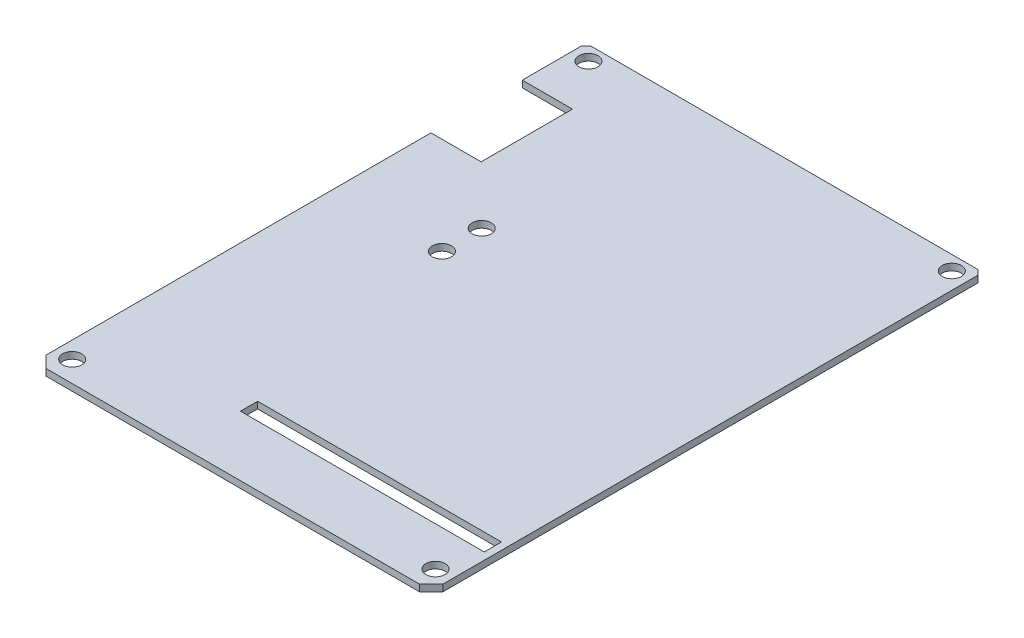
from build123d import *

# Parameters (mm, degrees)
SKETCH1_R           = 1
BOSS_EXTRUDE1_DEPTH = 0.7
SKETCH2_W           = 25.502878438
SKETCH2_H           = 1.8
CUT_EXTRUDE1_DEPTH  = 10
BOSS_EXTRUDE2_DEPTH = 0.7
SKETCH6_W           = 5.25
SKETCH6_H           = 9.55
CUT_EXTRUDE2_DEPTH  = 6


with BuildPart() as part:
    # Sketch1 → Boss-Extrude1 (new body)
    with BuildSketch(Plane(origin=(0, 0, 0), x_dir=(1, 0, 0), z_dir=(0, 1, 0))):
        Polygon((20.240139403, -28.5), (20.75, -27.990139403), (20.75, 27.990139403), (20.240139403, 28.5), (-20.240139403, 28.5), (-20.75, 27.990139403), (-20.75, -27.990139403), (-20.240139403, -28.5), align=None)
        with Locations((-19, -27)):
            Circle(SKETCH1_R, mode=Mode.SUBTRACT)
        with Locations((19, -27)):
            Circle(SKETCH1_R, mode=Mode.SUBTRACT)
        with Locations((-9.45, 2.115469811)):
            Circle(SKETCH1_R, mode=Mode.SUBTRACT)
        with Locations((-9.45, 6.284530189)):
            Circle(SKETCH1_R, mode=Mode.SUBTRACT)
        with Locations((-19, 27)):
            Circle(SKETCH1_R, mode=Mode.SUBTRACT)
        with Locations((19, 27)):
            Circle(SKETCH1_R, mode=Mode.SUBTRACT)
    extrude(amount=BOSS_EXTRUDE1_DEPTH)

    # Sketch2 → Cut-Extrude1 (cut)
    with BuildSketch(Plane(origin=(0, 0.7, 0), x_dir=(1, 0, 0), z_dir=(0, 1, 0))):
        with Locations((7.248560781, -22)):
            Rectangle(SKETCH2_W, SKETCH2_H)
    extrude(amount=-CUT_EXTRUDE1_DEPTH, mode=Mode.SUBTRACT)

    # Sketch5 → Boss-Extrude2 (add)
    with BuildSketch(Plane(origin=(0, 0.7, 0), x_dir=(1, 0, 0), z_dir=(0, 1, 0))):
        Polygon((-19.540139403, -29.2), (19.540139403, -29.2), (20.240139403, -28.5), (-20.240139403, -28.5), align=None)
    extrude(amount=-BOSS_EXTRUDE2_DEPTH)

    # Sketch6 → Cut-Extrude2 (cut)
    with BuildSketch(Plane(origin=(0, 0.7, 0), x_dir=(1, 0, 0), z_dir=(0, 1, 0))):
        with Locations((-18.125, 17.048605705)):
            Rectangle(SKETCH6_W, SKETCH6_H)
    extrude(amount=-CUT_EXTRUDE2_DEPTH, mode=Mode.SUBTRACT)


solid = part.part
